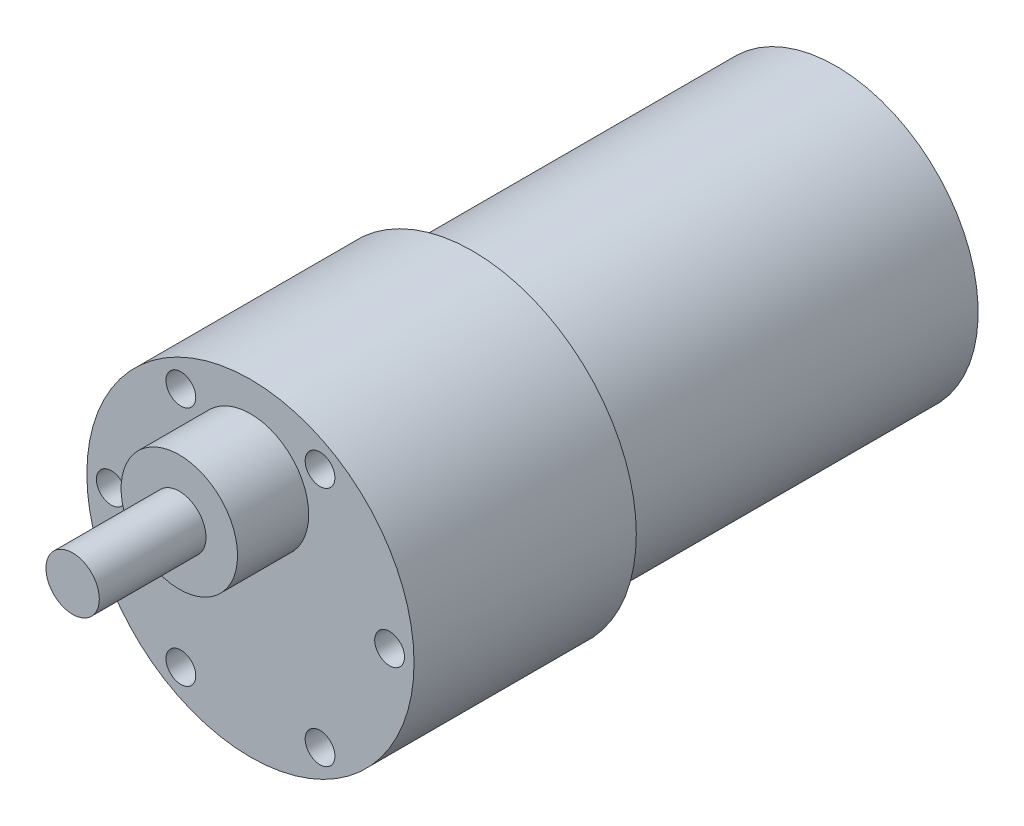
from build123d import *

# Parameters (mm, degrees)
SKETCH1_R           = 18.4
BOSS_EXTRUDE1_DEPTH = 25
SKETCH2_R           = 16
BOSS_EXTRUDE2_DEPTH = 40.85
SKETCH3_R           = 1.675
CUT_EXTRUDE1_DEPTH  = 10
SKETCH4_R           = 6.55
BOSS_EXTRUDE3_DEPTH = 8
SKETCH5_R           = 3
BOSS_EXTRUDE4_DEPTH = 12


with BuildPart() as part:
    # Sketch1 → Boss-Extrude1 (new body)
    with BuildSketch(Plane.XY):
        Circle(SKETCH1_R)
    extrude(amount=-BOSS_EXTRUDE1_DEPTH)

    # Sketch2 → Boss-Extrude2 (add)
    with BuildSketch(Plane(origin=(0, 0, -25), x_dir=(-1, 0, 0), z_dir=(0, 0, -1))):
        Circle(SKETCH2_R)
    extrude(amount=BOSS_EXTRUDE2_DEPTH)

    # Sketch3 → Cut-Extrude1 (cut)
    with BuildSketch(Plane.XY):
        with Locations((15.65, 0)):
            Circle(SKETCH3_R)
        with Locations((7.825, -13.553297569)):
            Circle(SKETCH3_R)
        with Locations((-7.825, -13.553297569)):
            Circle(SKETCH3_R)
        with Locations((-15.65, 0)):
            Circle(SKETCH3_R)
        with Locations((-7.825, 13.553297569)):
            Circle(SKETCH3_R)
        with Locations((7.825, 13.553297569)):
            Circle(SKETCH3_R)
    extrude(amount=-CUT_EXTRUDE1_DEPTH, mode=Mode.SUBTRACT)

    # Sketch4 → Boss-Extrude3 (add)
    with BuildSketch(Plane.XY):
        with Locations((0, 8.5)):
            Circle(SKETCH4_R)
    extrude(amount=BOSS_EXTRUDE3_DEPTH)

    # Sketch5 → Boss-Extrude4 (add)
    with BuildSketch(Plane.XY.offset(8)):
        with Locations((0, 8.5)):
            Circle(SKETCH5_R)
    extrude(amount=BOSS_EXTRUDE4_DEPTH)


solid = part.part
